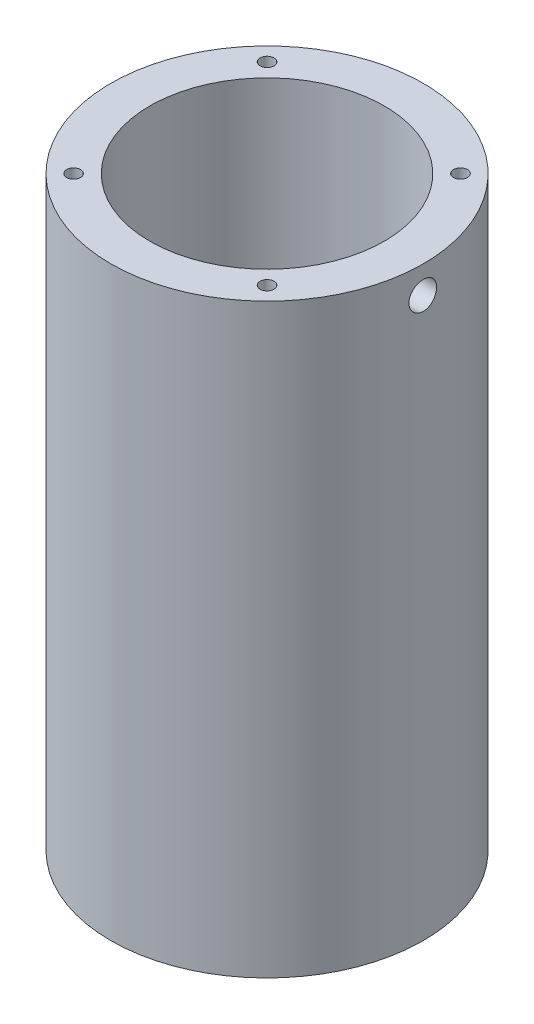
from build123d import *

# Parameters (mm, degrees)
SKETCH1_R                      = 25.4
SKETCH1_R_2                    = 19.05
BOSS_EXTRUDE1_DEPTH            = 95.25
F_4_40_TAPPED_HOLE1_AT_2_COUNT = 2
F_4_40_TAPPED_HOLE1_AT_2_PITCH = 31.430896424
F_4_40_TAPPED_HOLE1_AT_3_COUNT = 2
F_4_40_TAPPED_HOLE1_AT_3_PITCH = 44.45
F_4_40_TAPPED_HOLE1_AT_4_COUNT = 2
F_4_40_TAPPED_HOLE1_AT_4_PITCH = 31.430896424
F_4_40_TAPPED_HOLE1_AT_5_COUNT = 2
F_4_40_TAPPED_HOLE1_AT_5_PITCH = 22.225
SKETCH7_W                      = 2.2479
SKETCH7_H                      = 25.4


with BuildPart() as part:
    # Sketch1 → Boss-Extrude1 (new body)
    with BuildSketch(Plane(origin=(0, 0, 0), x_dir=(1, 0, 0), z_dir=(0, 1, 0))):
        Circle(SKETCH1_R)
        Circle(SKETCH1_R_2, mode=Mode.SUBTRACT)
    extrude(amount=BOSS_EXTRUDE1_DEPTH)

    # Sketch2 → #4-40 Tapped Hole1 (revolve, cut)
    with BuildSketch(Plane(origin=(-15.715448212, 0, -15.715448212), x_dir=(0, 0, -1), z_dir=(1, 0, 0))):
        Polygon((0, 0), (0, 8.934152758), (1.1303, 8.255), (1.1303, 0), align=None)
    f_4_40_tapped_hole1 = revolve(axis=Axis((-15.715448212, -6.35, -15.715448212), (0, 1, 0)), mode=Mode.SUBTRACT)

    # #4-40 Tapped Hole1 at 2: #4-40 Tapped Hole1 ×2
    with Locations(*[(0, 0, i * F_4_40_TAPPED_HOLE1_AT_2_PITCH) for i in range(1, F_4_40_TAPPED_HOLE1_AT_2_COUNT)]):
        add(f_4_40_tapped_hole1, mode=Mode.SUBTRACT)

    # #4-40 Tapped Hole1 at 3: #4-40 Tapped Hole1 ×2
    with Locations(*[Vector(0.707106781, 0, 0.707106781) * (i * F_4_40_TAPPED_HOLE1_AT_3_PITCH) for i in range(1, F_4_40_TAPPED_HOLE1_AT_3_COUNT)]):
        add(f_4_40_tapped_hole1, mode=Mode.SUBTRACT)

    # #4-40 Tapped Hole1 at 4: #4-40 Tapped Hole1 ×2
    with Locations(*[(i * F_4_40_TAPPED_HOLE1_AT_4_PITCH, 0, 0) for i in range(1, F_4_40_TAPPED_HOLE1_AT_4_COUNT)]):
        add(f_4_40_tapped_hole1, mode=Mode.SUBTRACT)

    # #4-40 Tapped Hole1 at 5: #4-40 Tapped Hole1 ×2
    with Locations(*[Vector(0.707106781, 0, 0.707106781) * (i * F_4_40_TAPPED_HOLE1_AT_5_PITCH) for i in range(1, F_4_40_TAPPED_HOLE1_AT_5_COUNT)]):
        add(f_4_40_tapped_hole1, mode=Mode.SUBTRACT)

    # Mirror1: #4-40 Tapped Hole1 across plane
    add(f_4_40_tapped_hole1.mirror(Plane(origin=(0, 47.625, 0), x_dir=(0, 0, 1), z_dir=(0, -1, 0))), mode=Mode.SUBTRACT)

    # Mirror1 copy 1 sketch → Mirror1 copy 1 (revolve, cut)
    with BuildSketch(Plane(origin=(-15.715448212, 95.25, 15.715448212), x_dir=(0, 0, -1), z_dir=(1, 0, 0))):
        Polygon((0, 0), (0, -8.934152758), (1.1303, -8.255), (1.1303, 0), align=None)
    revolve(axis=Axis((-15.715448212, 101.6, 15.715448212), (0, 1, 0)), mode=Mode.SUBTRACT)

    # Mirror1 copy 2 sketch → Mirror1 copy 2 (revolve, cut)
    with BuildSketch(Plane(origin=(15.715448212, 95.25, 15.715448212), x_dir=(0, 0, -1), z_dir=(1, 0, 0))):
        Polygon((0, 0), (0, -8.934152758), (1.1303, -8.255), (1.1303, 0), align=None)
    revolve(axis=Axis((15.715448212, 101.6, 15.715448212), (0, 1, 0)), mode=Mode.SUBTRACT)

    # Mirror1 copy 3 sketch → Mirror1 copy 3 (revolve, cut)
    with BuildSketch(Plane(origin=(15.715448212, 95.25, -15.715448212), x_dir=(0, 0, -1), z_dir=(1, 0, 0))):
        Polygon((0, 0), (0, -8.934152758), (1.1303, -8.255), (1.1303, 0), align=None)
    revolve(axis=Axis((15.715448212, 101.6, -15.715448212), (0, 1, 0)), mode=Mode.SUBTRACT)

    # Mirror1 copy 4 sketch → Mirror1 copy 4 (revolve, cut)
    with BuildSketch(Plane(origin=(0, 95.25, 0), x_dir=(0, 0, -1), z_dir=(1, 0, 0))):
        Polygon((0, 0), (0, -8.934152758), (1.1303, -8.255), (1.1303, 0), align=None)
    revolve(axis=Axis((0, 101.6, 0), (0, 1, 0)), mode=Mode.SUBTRACT)

    # Sketch7 → #8 Clearance Hole1 (revolve, cut)
    with BuildSketch(Plane.ZX.offset(90.805)):
        with Locations((1.12395, 12.7)):
            Rectangle(SKETCH7_W, SKETCH7_H)
    revolve(axis=Axis((-6.35, 90.805, 0), (1, 0, 0)), mode=Mode.SUBTRACT)


solid = part.part
